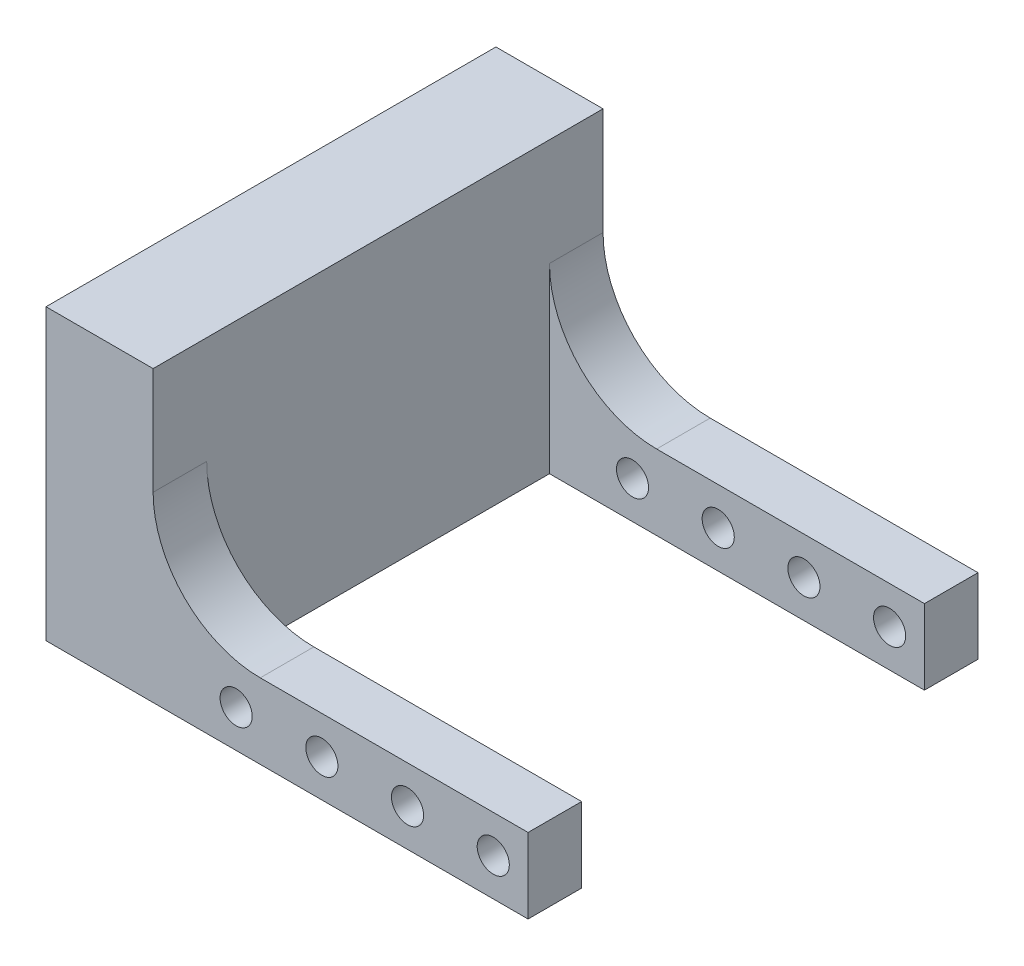
from build123d import *

# Parameters (mm, degrees)
BOSS_EXTRU_1_DEPTH      = 42
ESQUISSE3_W             = 35
ESQUISSE3_H             = 32
ENL_V_MAT_EXTRU_2_DEPTH = 8
ESQUISSE2_R             = 1.5
ENL_V_MAT_EXTRU_3_DEPTH = 43
CONG_1_R                = 10


with BuildPart() as part:
    # Esquisse1 → Boss.-Extru.1 (new body)
    with BuildSketch(Plane.XY):
        Polygon((0, 7), (0, 27), (-10, 27), (-10, 0), (0, 0), (35, 0), (35, 7), align=None)
    extrude(amount=BOSS_EXTRU_1_DEPTH)

    # Esquisse3 → Enlèv. mat.-Extru.2 (cut, through all)
    with BuildSketch(Plane(origin=(0, 7, 0), x_dir=(1, 0, 0), z_dir=(0, 1, 0))):
        with Locations((17.5, -21)):
            Rectangle(ESQUISSE3_W, ESQUISSE3_H)
    extrude(amount=-ENL_V_MAT_EXTRU_2_DEPTH, mode=Mode.SUBTRACT)

    # Esquisse2 → Enlèv. mat.-Extru.3 (cut, through all)
    with BuildSketch(Plane.XY.offset(42)):
        with Locations((31.75, 3.5)):
            Circle(ESQUISSE2_R)
        with Locations((23.75, 3.5)):
            Circle(ESQUISSE2_R)
        with Locations((15.75, 3.5)):
            Circle(ESQUISSE2_R)
        with Locations((7.75, 3.5)):
            Circle(ESQUISSE2_R)
    extrude(amount=-ENL_V_MAT_EXTRU_3_DEPTH, mode=Mode.SUBTRACT)

    # Congé1
    cong_1_edges = [part.edges().sort_by_distance(p)[0] for p in [
        (0, 7, 39.5),
        (0, 7, 2.5),
    ]]
    fillet(cong_1_edges, radius=CONG_1_R)


solid = part.part
